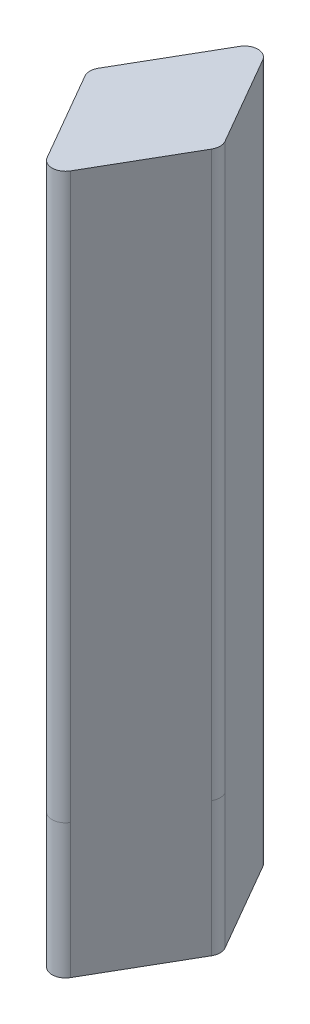
from build123d import *

# Parameters (mm, degrees)
BOSS_EXTRUDE1_DEPTH = 52
CUT_EXTRUDE1_DEPTH  = 45
SKETCH3_R           = 1.5
CUT_EXTRUDE2_DEPTH  = 8
BOSS_EXTRUDE2_DEPTH = 1
CUT_EXTRUDE5_DEPTH  = 10
FILLET1_R           = 1


with BuildPart() as part:
    # Sketch1 → Boss-Extrude1 (new body)
    with BuildSketch(Plane(origin=(0, 0, 0), x_dir=(1, 0, 0), z_dir=(0, 1, 0))):
        Polygon((-5, 0), (0, 8.660254), (5, 0), (0, -8.660254), align=None)
    extrude(amount=-BOSS_EXTRUDE1_DEPTH)

    # Sketch2 → Cut-Extrude1 (cut)
    with BuildSketch(Plane(origin=(0, 0, 0), x_dir=(1, 0, 0), z_dir=(0, 1, 0))):
        Polygon((0, 6.660254), (-3.845299, 0), (0, -6.660254), (3.845299, 0), align=None)
    extrude(amount=-CUT_EXTRUDE1_DEPTH, mode=Mode.SUBTRACT)

    # Sketch3 → Cut-Extrude2 (cut, through all)
    with BuildSketch(Plane(origin=(0, -45, 0), x_dir=(1, 0, 0), z_dir=(0, 1, 0))):
        Circle(SKETCH3_R)
    extrude(amount=-CUT_EXTRUDE2_DEPTH, mode=Mode.SUBTRACT)

    # Sketch5 → Boss-Extrude2 (add)
    with BuildSketch(Plane(origin=(0, 0, 0), x_dir=(1, 0, 0), z_dir=(0, 1, 0))):
        Polygon((-3.845299, 0), (0, 6.660254), (3.845299, 0), (0, -6.660254), align=None)
    extrude(amount=-BOSS_EXTRUDE2_DEPTH)

    # Sketch12 → Cut-Extrude5 (cut)
    with BuildSketch(Plane.XZ.offset(52)):
        with BuildLine():
            Line((-0.866025, 7.160254), (0, 8.660254))
            Line((0, 8.660254), (0.866025, 7.160254))
            ThreePointArc((0.866025, 7.160254), (0, 7.660254), (-0.866025, 7.160254))
        make_face()
        with BuildLine():
            Line((-4.711325, 0.5), (-5, 0))
            Line((-5, 0), (-4.711325, -0.5))
            ThreePointArc((-4.711325, -0.5), (-4.845299, 0), (-4.711325, 0.5))
        make_face()
        with BuildLine():
            Line((-0.866025, -7.160254), (0, -8.660254))
            Line((0, -8.660254), (0.866025, -7.160254))
            ThreePointArc((0.866025, -7.160254), (0, -7.660254), (-0.866025, -7.160254))
        make_face()
        with BuildLine():
            Line((4.711325, 0.5), (5, 0))
            Line((5, 0), (4.711325, -0.5))
            ThreePointArc((4.711325, -0.5), (4.845299, 0), (4.711325, 0.5))
        make_face()
    extrude(amount=-CUT_EXTRUDE5_DEPTH, mode=Mode.SUBTRACT)

    # Fillet1
    fillet1_edges = [part.edges().sort_by_distance(p)[0] for p in [
        (-5, -21, 0),
        (0, -21, 8.660254),
        (5, -21, 0),
        (0, -21, -8.660254),
    ]]
    fillet(fillet1_edges, radius=FILLET1_R)


solid = part.part
